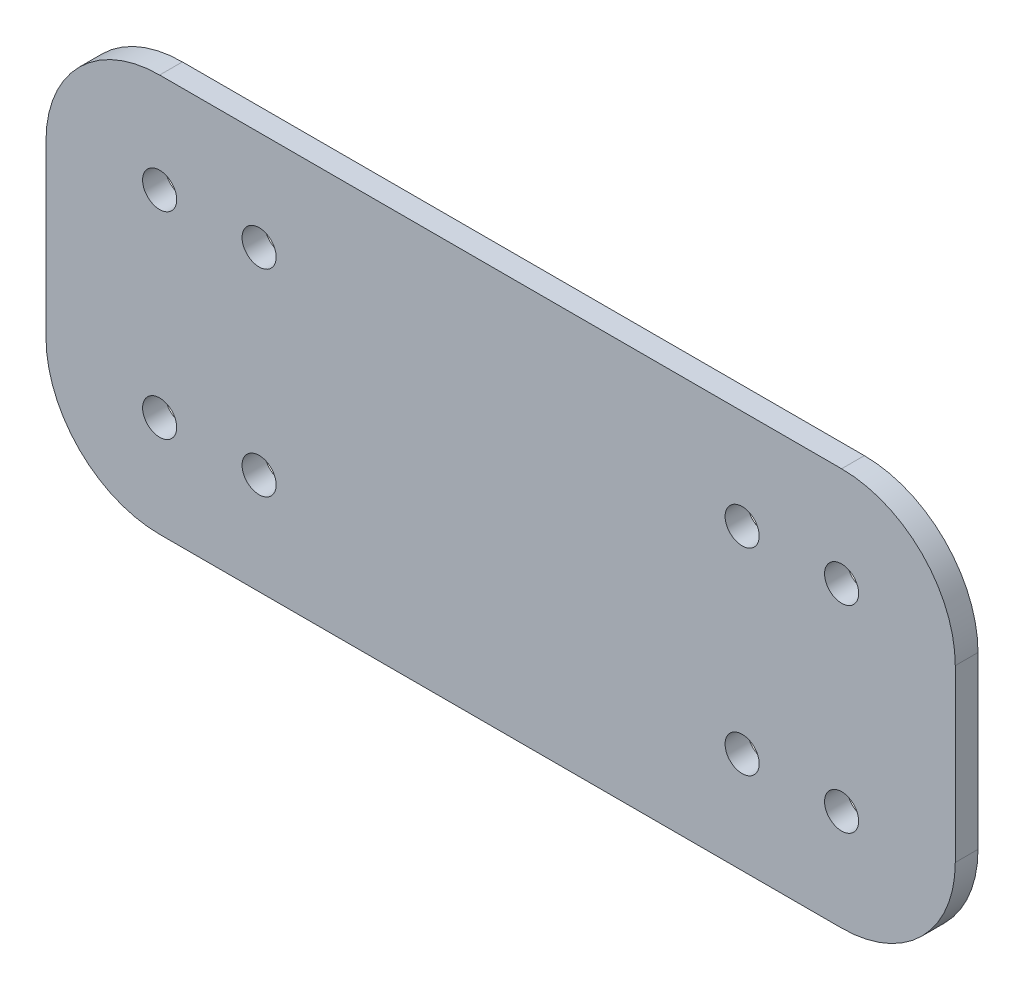
from build123d import *

# Parameters (mm, degrees)
EXTRUDE_1_DEPTH = 2
MM_2_D          = 3
MM_3_D          = 3


with BuildPart() as part:
    # 草图2 → 凸台-拉伸1 (new body)
    with BuildSketch(Plane.XY):
        with BuildLine():
            Line((-50.360367403, 22.370399323), (9.639632597, 22.370399323))
            ThreePointArc((9.639632597, 22.370399323), (16.710700409, 19.441467134), (19.639632597, 12.370399323))
            Line((19.639632597, 12.370399323), (19.639632597, -2.629600677))
            ThreePointArc((19.639632597, -2.629600677), (16.710700409, -9.700668489), (9.639632597, -12.629600677))
            Line((9.639632597, -12.629600677), (-50.360367403, -12.629600677))
            ThreePointArc((-50.360367403, -12.629600677), (-57.431435215, -9.700668489), (-60.360367403, -2.629600677))
            Line((-60.360367403, -2.629600677), (-60.360367403, 12.370399323))
            ThreePointArc((-60.360367403, 12.370399323), (-57.431435215, 19.441467134), (-50.360367403, 22.370399323))
        make_face()
    extrude(amount=EXTRUDE_1_DEPTH)

    # 大小mm 暗销孔2 (through all)
    with Locations(Plane(origin=(-41.610367403, 13.620399323, 0), x_dir=(-1, 0, 0), z_dir=(0, 0, -1))):
        with Locations((0, 0), (8.75, 0), (0, -17.352577314), (8.75, -17.352577314)):
            Hole(MM_2_D / 2)

    # 大小mm 暗销孔3 (through all)
    with Locations(Plane(origin=(9.639632597, 13.620399323, 0), x_dir=(-1, 0, 0), z_dir=(0, 0, -1))):
        with Locations((0, 0), (8.75, 0), (8.75, -17.352577314), (0, -17.352577314)):
            Hole(MM_3_D / 2)


solid = part.part
